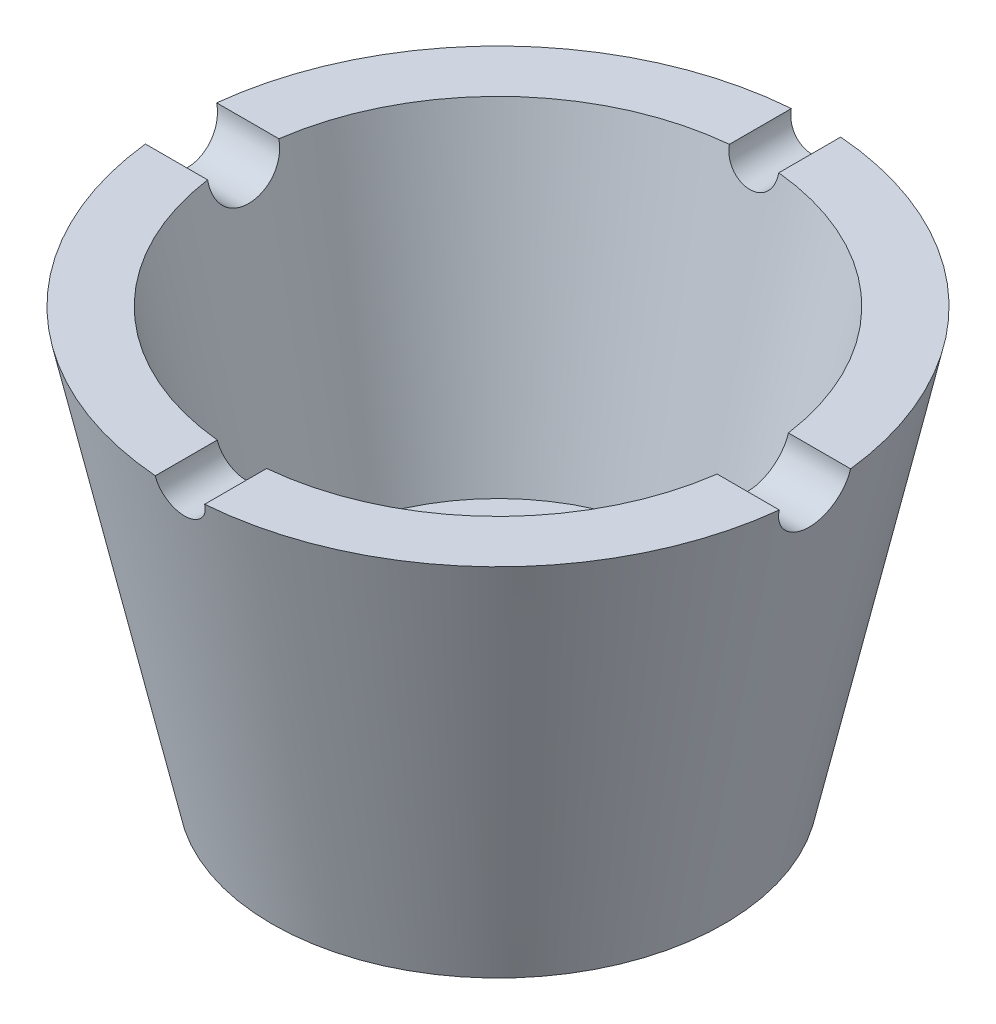
from build123d import *

# Parameters (mm, degrees)
CUT_EXTRUDE1_DEPTH = 50
CUT_EXTRUDE2_DEPTH = 50


with BuildPart() as part:
    # Sketch1 → Revolve1 (revolve)
    with BuildSketch(Plane.XY):
        Polygon((11.25, 10.82996466), (11.25, -1.17003534), (22.5, -1.17003534), (31.753664233, 40.82996466), (25.609760166, 40.82996466), (19, 10.82996466), align=None)
    revolve(axis=Axis((0, 29.136855034, 0), (0, -1, 0)))

    # Sketch2 → Cut-Extrude1 (cut, symmetric)
    with BuildSketch(Plane(origin=(0, 0, 0), x_dir=(0, 0, -1), z_dir=(1, 0, 0))):
        with BuildLine():
            Line((-3.547836686, 40.82996466), (3.547836686, 40.82996466))
            ThreePointArc((3.547836686, 40.82996466), (0, 37.282127974), (-3.547836686, 40.82996466))
        make_face()
    extrude(amount=CUT_EXTRUDE1_DEPTH, both=True, mode=Mode.SUBTRACT)

    # Sketch3 → Cut-Extrude2 (cut, symmetric)
    with BuildSketch(Plane.XY):
        with BuildLine():
            Line((-2.456970945, 40.82996466), (2.456970945, 40.82996466))
            ThreePointArc((2.456970945, 40.82996466), (0, 38.372993715), (-2.456970945, 40.82996466))
        make_face()
    extrude(amount=CUT_EXTRUDE2_DEPTH, both=True, mode=Mode.SUBTRACT)


solid = part.part
